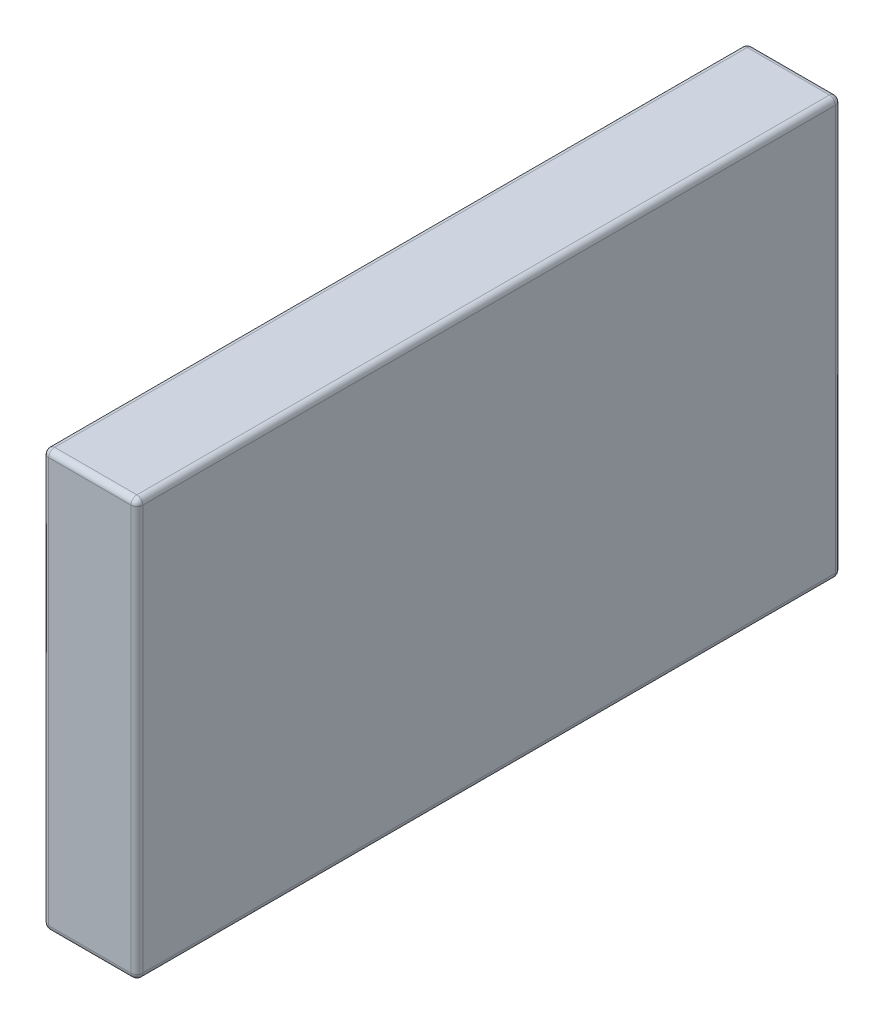
from build123d import *

# Parameters (mm, degrees)
SKETCH1_W           = 20.066
SKETCH1_H           = 150.114
BOSS_EXTRUDE1_DEPTH = 44.45
FILLET1_R           = 1.27


with BuildPart() as part:
    # Sketch1 → Boss-Extrude1 (new body, symmetric)
    with BuildSketch(Plane(origin=(0, 0, 0), x_dir=(1, 0, 0), z_dir=(0, 1, 0))):
        Rectangle(SKETCH1_W, SKETCH1_H)
    extrude(amount=BOSS_EXTRUDE1_DEPTH, both=True)

    # Fillet1
    fillet1_edges = [part.edges().sort_by_distance(p)[0] for p in [
        (10.033, 44.45, 0),
        (0, 44.45, -75.057),
        (-10.033, 44.45, 0),
        (0, -44.45, -75.057),
        (10.033, -44.45, 0),
        (0, -44.45, 75.057),
        (-10.033, -44.45, 0),
        (-10.033, 0, -75.057),
        (10.033, 0, -75.057),
        (10.033, 0, 75.057),
        (-10.033, 0, 75.057),
        (0, 44.45, 75.057),
    ]]
    fillet(fillet1_edges, radius=FILLET1_R)


solid = part.part
